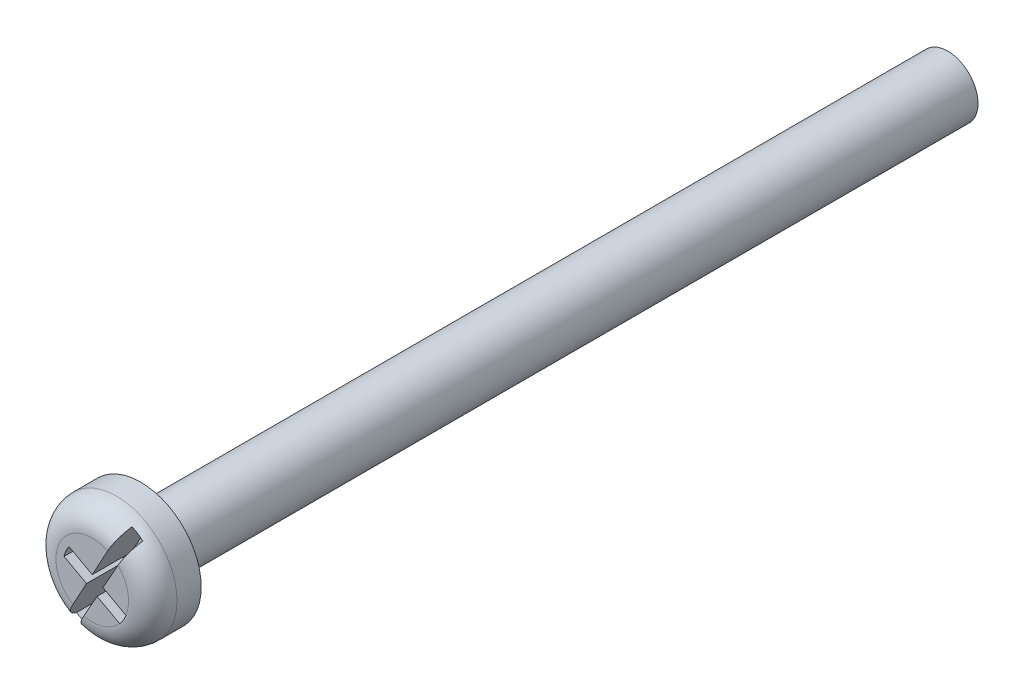
from build123d import *

# Parameters (mm, degrees)
SZKIC1_R                    = 3
DODANIE_WYCI_GNI_CIE2_DEPTH = 2.4
SZKIC2_R                    = 1.5
DODANIE_WYCI_GNI_CIE3_DEPTH = 40
ZAOKR_GLENIE2_R             = 1.2
WYTNIJ_WYCI_GNI_CIE1_DEPTH  = 1.94


with BuildPart() as part:
    # Szkic1 → Dodanie-wyciągnięcie2 (new body)
    with BuildSketch(Plane.XY):
        with Locations((-1.860516246, 2.732142857)):
            Circle(SZKIC1_R)
    extrude(amount=DODANIE_WYCI_GNI_CIE2_DEPTH)

    # Szkic2 → Dodanie-wyciągnięcie3 (add)
    with BuildSketch(Plane(origin=(0, 0, 0), x_dir=(-1, 0, 0), z_dir=(0, 0, -1))):
        with Locations((1.860516246, 2.732142857)):
            Circle(SZKIC2_R)
    extrude(amount=DODANIE_WYCI_GNI_CIE3_DEPTH)

    # Zaokrąglenie2
    zaokr_glenie2_edges = [part.edges().sort_by_distance(p)[0] for p in [
        (-4.860516246, 2.732142857, 2.4),
    ]]
    fillet(zaokr_glenie2_edges, radius=ZAOKR_GLENIE2_R)

    # Szkic3 → Wytnij-wyciągnięcie1 (cut)
    with BuildSketch(Plane.XY.offset(2.4)):
        with BuildLine():
            Line((-1.859548318, 2.959091853), (-0.575649693, 5.316481314))
            ThreePointArc((-0.575649693, 5.316481314), (-0.297886623, 5.158637444), (-0.039271083, 4.97106076))
            Line((-0.039271083, 4.97106076), (-1.329373025, 2.669425378))
            Line((-1.329373025, 2.669425378), (-0.183967515, 2.043621837))
            ThreePointArc((-0.183967515, 2.043621837), (-0.320475658, 1.776553075), (-0.499159616, 1.535654258))
            Line((-0.499159616, 1.535654258), (-1.621312108, 2.148584891))
            Line((-1.621312108, 2.148584891), (-2.819933608, 0.01015725))
            ThreePointArc((-2.819933608, 0.01015725), (-3.083174674, 0.117799023), (-3.33454353, 0.250826496))
            Line((-3.33454353, 0.250826496), (-2.145142944, 2.434706401))
            Line((-2.145142944, 2.434706401), (-3.258687897, 3.042935511))
            ThreePointArc((-3.258687897, 3.042935511), (-3.162842423, 3.328316127), (-3.009463836, 3.587359481))
            Line((-3.009463836, 3.587359481), (-1.859548318, 2.959091853))
        make_face()
    extrude(amount=-WYTNIJ_WYCI_GNI_CIE1_DEPTH, mode=Mode.SUBTRACT)


solid = part.part
